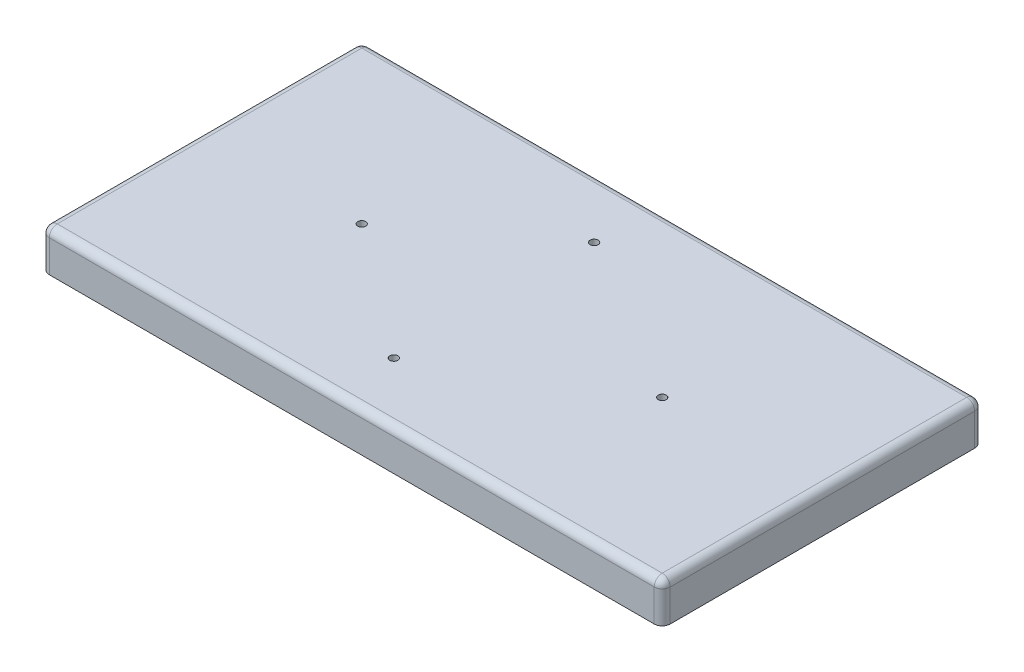
from build123d import *

# Parameters (mm, degrees)
SKETCH2_W           = 155
SKETCH2_H           = 80
SKETCH2_R           = 1
BOSS_EXTRUDE1_DEPTH = 5
SKETCH3_W           = 155
SKETCH3_H           = 80
SKETCH3_W_2         = 149
SKETCH3_H_2         = 74
BOSS_EXTRUDE2_DEPTH = 10
SKETCH4_W           = 155
SKETCH4_H           = 80
SKETCH4_W_2         = 145
SKETCH4_H_2         = 70
BOSS_EXTRUDE3_DEPTH = 7
FILLET1_R           = 2


with BuildPart() as part:
    # Sketch2 → Boss-Extrude1 (new body)
    with BuildSketch(Plane(origin=(0, 0, 0), x_dir=(1, 0, 0), z_dir=(0, 1, 0))):
        with Locations((77.5, 40)):
            Rectangle(SKETCH2_W, SKETCH2_H)
        with Locations(Location((40, 40, 0), (0, 0, 270))):  # turned: the seam where the file's is
            Circle(SKETCH2_R, mode=Mode.SUBTRACT)
        with Locations(Location((115, 40, 0), (0, 0, 270))):  # turned: the seam where the file's is
            Circle(SKETCH2_R, mode=Mode.SUBTRACT)
        with Locations(Location((73, 65, 0), (0, 0, 270))):  # turned: the seam where the file's is
            Circle(SKETCH2_R, mode=Mode.SUBTRACT)
        with Locations(Location((73, 15, 0), (0, 0, 270))):  # turned: the seam where the file's is
            Circle(SKETCH2_R, mode=Mode.SUBTRACT)
    extrude(amount=-BOSS_EXTRUDE1_DEPTH)

    # Sketch3 → Boss-Extrude2 (add)
    with BuildSketch(Plane(origin=(0, 0, 0), x_dir=(1, 0, 0), z_dir=(0, 1, 0))):
        with Locations((77.5, 40)):
            Rectangle(SKETCH3_W, SKETCH3_H)
        with Locations((77.5, 40)):
            Rectangle(SKETCH3_W_2, SKETCH3_H_2, mode=Mode.SUBTRACT)
    extrude(amount=-BOSS_EXTRUDE2_DEPTH)

    # Sketch4 → Boss-Extrude3 (add)
    with BuildSketch(Plane(origin=(0, 0, 0), x_dir=(1, 0, 0), z_dir=(0, 1, 0))):
        with Locations((77.5, 40)):
            Rectangle(SKETCH4_W, SKETCH4_H)
        with Locations((77.5, 40)):
            Rectangle(SKETCH4_W_2, SKETCH4_H_2, mode=Mode.SUBTRACT)
    extrude(amount=-BOSS_EXTRUDE3_DEPTH)

    # Fillet1
    fillet1_edges = [part.edges().sort_by_distance(p)[0] for p in [
        (77.5, 0, -80),
        (155, 0, -40),
        (77.5, 0, 0),
        (0, 0, -40),
        (0, -5, -80),
        (155, -5, -80),
        (155, -5, 0),
        (0, -5, 0),
    ]]
    fillet(fillet1_edges, radius=FILLET1_R)


solid = part.part
